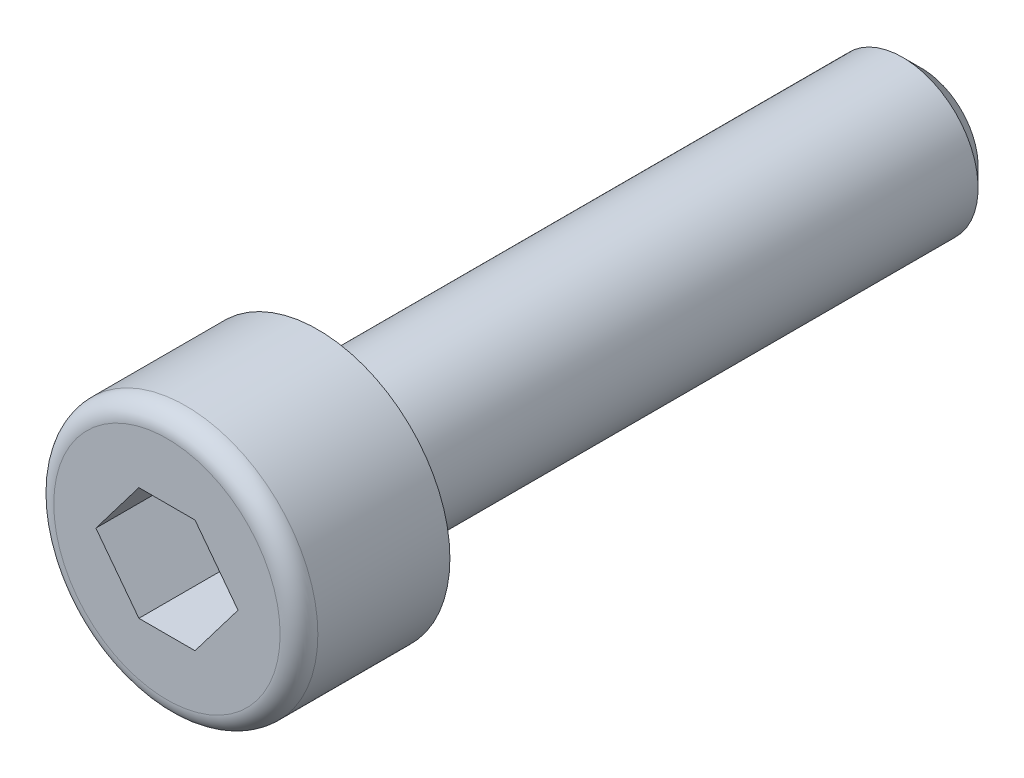
from build123d import *

# Parameters (mm, degrees)
ESQUISSE1_R             = 3.5
BASE_EXTRUSION_DEPTH    = 4
ESQUISSE2_R             = 2
BOSS_EXTRU_1_DEPTH      = 16
ENL_V_MAT_EXTRU_1_DEPTH = 4
CONG_1_R                = 0.5
CHANFREIN1_SIZE         = 0.5


with BuildPart() as part:
    # Esquisse1 → Base-Extrusion (new body)
    with BuildSketch(Plane.XY):
        Circle(ESQUISSE1_R)
    extrude(amount=BASE_EXTRUSION_DEPTH)

    # Esquisse2 → Boss.-Extru.1 (add)
    with BuildSketch(Plane(origin=(0, 0, 0), x_dir=(-1, 0, 0), z_dir=(0, 0, -1))):
        Circle(ESQUISSE2_R)
    extrude(amount=BOSS_EXTRU_1_DEPTH)

    # Esquisse3 → Enlèv. mat.-Extru.1 (cut)
    with BuildSketch(Plane.XY.offset(4)):
        Polygon((1.884038216, 0), (0.744038216, 1.5), (-0.744038216, 1.5), (-1.884038216, 0), (-0.744038216, -1.5), (0.744038216, -1.5), align=None)
    extrude(amount=-ENL_V_MAT_EXTRU_1_DEPTH, mode=Mode.SUBTRACT)

    # Congé1
    cong_1_edges = [part.edges().sort_by_distance(p)[0] for p in [
        (-3.5, 0, 4),
    ]]
    fillet(cong_1_edges, radius=CONG_1_R)

    # Chanfrein1
    chanfrein1_edges = [part.edges().sort_by_distance(p)[0] for p in [
        (2, 0, -16),
    ]]
    chamfer(chanfrein1_edges, length=CHANFREIN1_SIZE)


solid = part.part
